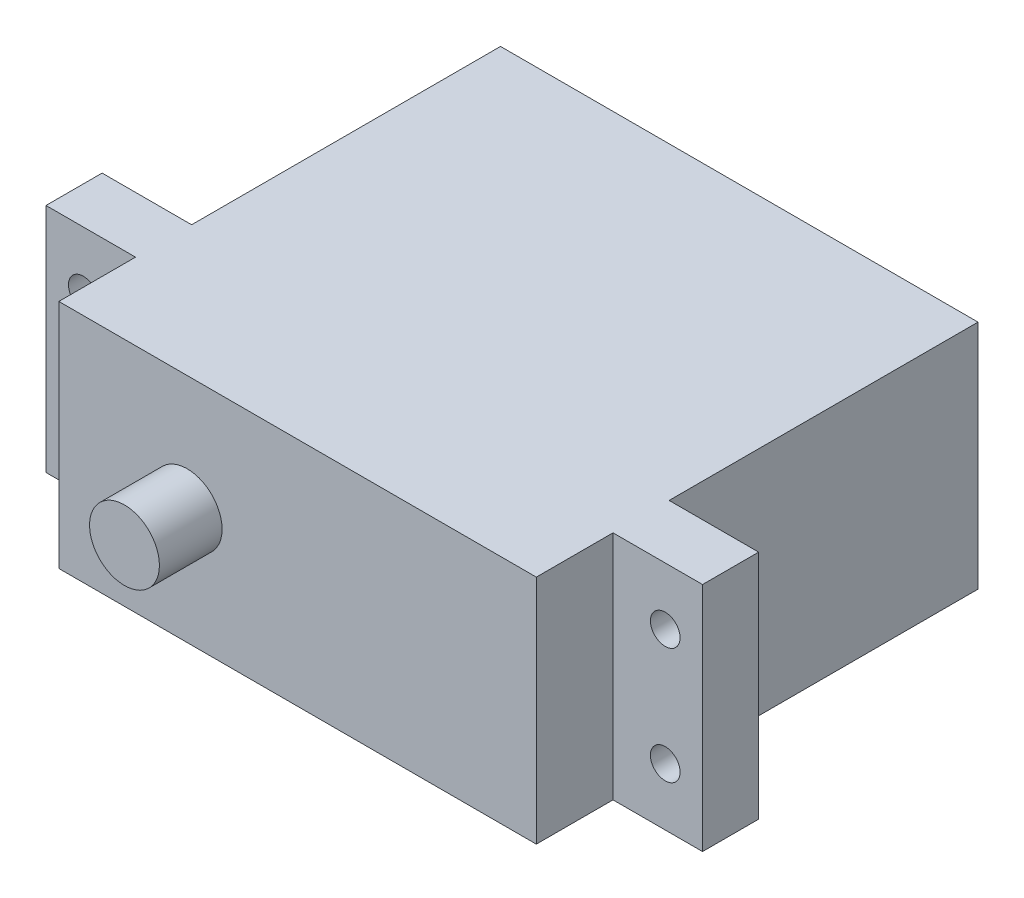
from build123d import *

# Parameters (mm, degrees)
SKETCH1_W                        = 55.88
SKETCH1_H                        = 19.685
EXTRUDE1_DEPTH                   = 42.926
SKETCH3_OUTSIDE_W                = 72.512
SKETCH3_OUTSIDE_H                = 36.318
SKETCH3_OUTSIDE_R                = 2.9718
EXTRUDE2_DEPTH                   = 5.334
SKETCH8_W                        = 7.62
SKETCH8_H                        = 19.685
EXTRUDE5_DEPTH                   = 26.289
F_39_0_0995_DIAMETER_HOLE1_D     = 2.5273
F_39_0_0995_DIAMETER_HOLE1_DEPTH = 12.7
F_39_0_0995_DIAMETER_HOLE1_TIP   = 0.759277521
SKETCH13_W                       = 7.62
SKETCH13_H                       = 19.685
EXTRUDE6_DEPTH                   = 6.5278


with BuildPart() as part:
    # Sketch1 → Extrude1 (new body)
    with BuildSketch(Plane.XY):
        Rectangle(SKETCH1_W, SKETCH1_H)
    extrude(amount=EXTRUDE1_DEPTH)

    # Sketch3 outside → Extrude2 (cut)
    with BuildSketch(Plane.XY.offset(42.926)):
        Rectangle(SKETCH3_OUTSIDE_W, SKETCH3_OUTSIDE_H)
        with Locations((-9.398, 0)):
            Circle(SKETCH3_OUTSIDE_R, mode=Mode.SUBTRACT)
    extrude(amount=-EXTRUDE2_DEPTH, mode=Mode.SUBTRACT)

    # Sketch8 → Extrude5 (cut)
    with BuildSketch(Plane(origin=(0, 0, 0), x_dir=(-1, 0, 0), z_dir=(0, 0, -1))):
        with Locations((-24.13, 0)):
            Rectangle(SKETCH8_W, SKETCH8_H)
        with Locations((24.13, 0)):
            Rectangle(SKETCH8_W, SKETCH8_H)
    extrude(amount=-EXTRUDE5_DEPTH, mode=Mode.SUBTRACT)

    # #39 (0.0995) Diameter Hole1
    with Locations(Plane(origin=(-24.765, 4.953, 37.592), x_dir=(1, 0, 0), z_dir=(0, 0, 1))):
        with Locations((0, 0), (0, -9.906), (49.53, 0), (49.53, -9.906)):
            Hole(F_39_0_0995_DIAMETER_HOLE1_D / 2, depth=F_39_0_0995_DIAMETER_HOLE1_DEPTH)
            with Locations((0, 0, -(F_39_0_0995_DIAMETER_HOLE1_DEPTH + F_39_0_0995_DIAMETER_HOLE1_TIP / 2))):  # 118° drill point
                Cone(0, F_39_0_0995_DIAMETER_HOLE1_D / 2, F_39_0_0995_DIAMETER_HOLE1_TIP, mode=Mode.SUBTRACT)

    # Sketch13 → Extrude6 (cut)
    with BuildSketch(Plane.XY.offset(37.592)):
        with Locations((-24.13, 0)):
            Rectangle(SKETCH13_W, SKETCH13_H)
        with Locations((24.13, 0)):
            Rectangle(SKETCH13_W, SKETCH13_H)
    extrude(amount=-EXTRUDE6_DEPTH, mode=Mode.SUBTRACT)


solid = part.part
